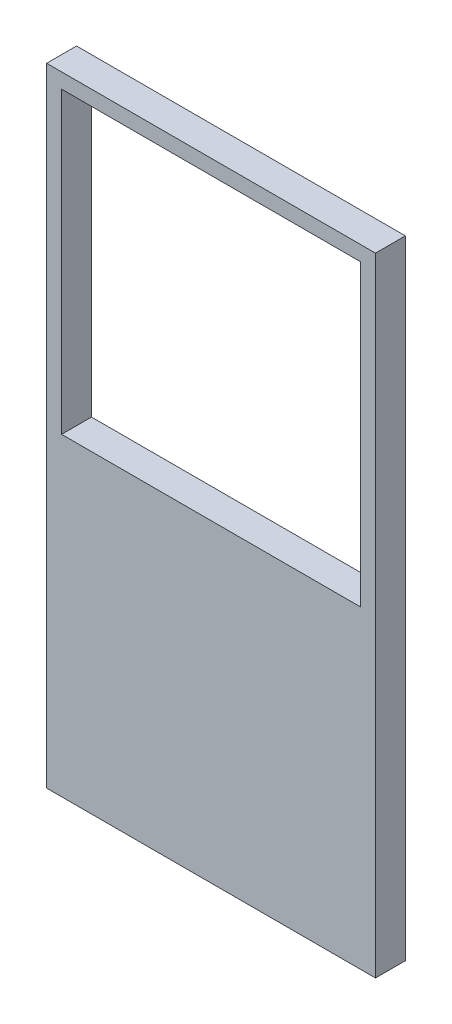
from build123d import *

# Parameters (mm, degrees)
SKETCH1_W           = 27.94
SKETCH1_H           = 27.94
SKETCH1_W_2         = 25.4
SKETCH1_H_2         = 25.4
EXTRUDE_THIN1_DEPTH = 1.27
SKETCH2_W           = 27.94
SKETCH2_H           = 25.4
BOSS_EXTRUDE1_DEPTH = 2.54


with BuildPart() as part:
    # Sketch1 → Extrude-Thin1 (new body, symmetric)
    with BuildSketch(Plane.XY):
        Rectangle(SKETCH1_W, SKETCH1_H)
        Rectangle(SKETCH1_W_2, SKETCH1_H_2, mode=Mode.SUBTRACT)
    extrude(amount=EXTRUDE_THIN1_DEPTH, both=True)

    # Sketch2 → Boss-Extrude1 (add, through all)
    with BuildSketch(Plane.XY.offset(1.27)):
        with Locations((0, -26.67)):
            Rectangle(SKETCH2_W, SKETCH2_H)
    extrude(amount=-BOSS_EXTRUDE1_DEPTH)


solid = part.part
